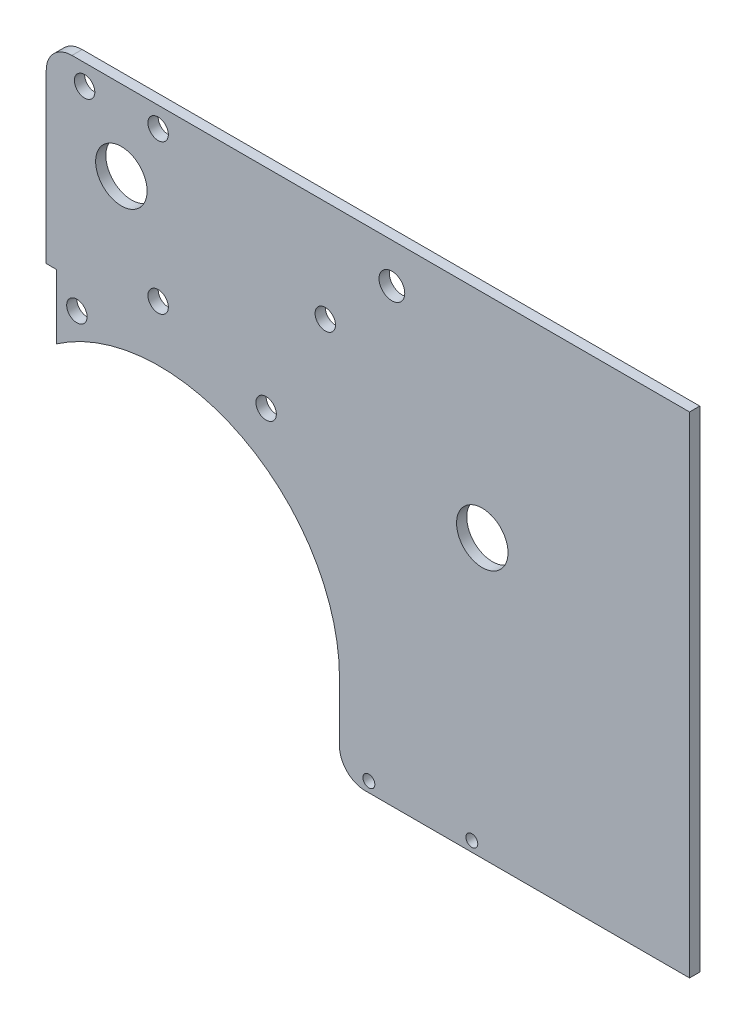
from build123d import *

# Parameters (mm, degrees)
SKETCH1_R           = 8
SKETCH1_R_2         = 3.175
SKETCH1_R_3         = 1.85
SKETCH1_R_4         = 4
BOSS_EXTRUDE1_DEPTH = 3.175
FILLET1_R           = 8
FILLET2_R           = 8


with BuildPart() as part:
    # Sketch1 → Boss-Extrude1 (new body)
    with BuildSketch(Plane.XY):
        with BuildLine():
            Line((176.640929786, -127.55), (67.815929786, -127.55))
            Line((67.815929786, -127.55), (67.815929786, -101.2))
            ThreePointArc((67.815929786, -101.2), (37.73889258, -51.561305416), (-20.184070214, -55.243498828))
            Line((-20.184070214, -55.243498828), (-20.184070214, -35.2))
            Line((-20.184070214, -35.2), (-23.359070214, -35.2))
            Line((-23.359070214, -35.2), (-23.359070214, 24.85))
            Line((-23.359070214, 24.85), (176.640929786, 24.85))
            Line((176.640929786, 24.85), (176.640929786, -127.55))
        make_face()
        with Locations((112.2, -41.275)):
            Circle(SKETCH1_R, mode=Mode.SUBTRACT)
        Circle(SKETCH1_R, mode=Mode.SUBTRACT)
        with Locations((11.43, -27.96)):
            Circle(SKETCH1_R_2, mode=Mode.SUBTRACT)
        with Locations((-11.43, 18.5)):
            Circle(SKETCH1_R_2, mode=Mode.SUBTRACT)
        with Locations((11.43, 18.5)):
            Circle(SKETCH1_R_2, mode=Mode.SUBTRACT)
        with Locations((45, -40)):
            Circle(SKETCH1_R_2, mode=Mode.SUBTRACT)
        with Locations((63.404393546, -6.8)):
            Circle(SKETCH1_R_2, mode=Mode.SUBTRACT)
        with Locations((108.95, -124.375)):
            Circle(SKETCH1_R_3, mode=Mode.SUBTRACT)
        with Locations((76.95, -124.375)):
            Circle(SKETCH1_R_3, mode=Mode.SUBTRACT)
        with Locations((-13.834070214, -43.2)):
            Circle(SKETCH1_R_2, mode=Mode.SUBTRACT)
        with Locations((84.102828318, 12.5)):
            Circle(SKETCH1_R_4, mode=Mode.SUBTRACT)
    extrude(amount=-BOSS_EXTRUDE1_DEPTH)

    # Fillet1
    fillet1_edges = [part.edges().sort_by_distance(p)[0] for p in [
        (67.815929786, -127.55, -1.5875),
    ]]
    fillet(fillet1_edges, radius=FILLET1_R)

    # Fillet2
    fillet2_edges = [part.edges().sort_by_distance(p)[0] for p in [
        (-23.359070214, 24.85, -1.5875),
    ]]
    fillet(fillet2_edges, radius=FILLET2_R)


solid = part.part
